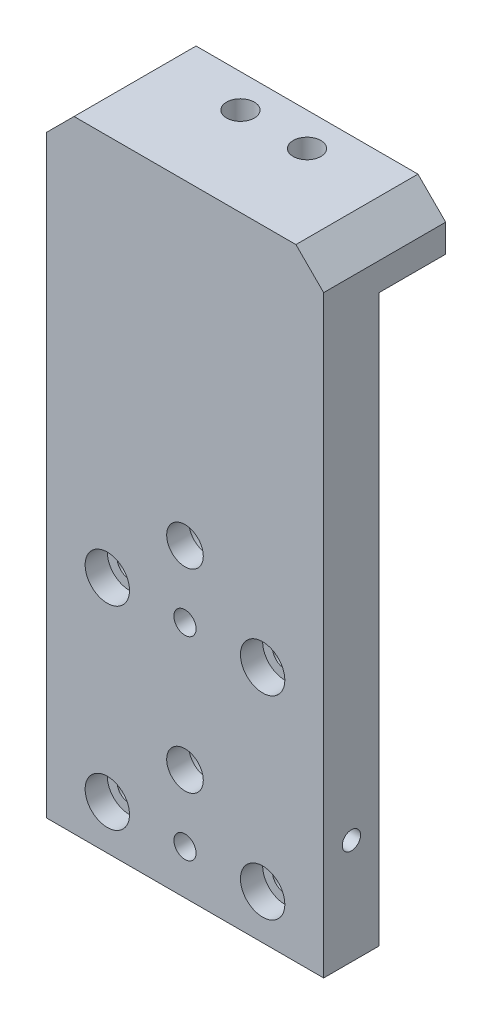
from build123d import *

# Parameters (mm, degrees)
SKETCH1_W             = 50
SKETCH1_H             = 112
SKETCH1_R             = 3.3
SKETCH1_R_2           = 2
SKETCH1_R_3           = 2.25
BOSS_EXTRUDE1_DEPTH   = 10
SKETCH2_R             = 5.5
CUT_EXTRUDE1_DEPTH    = 6
SKETCH3_R             = 4
CUT_EXTRUDE2_DEPTH    = 4
SKETCH4_W             = 50
SKETCH4_H             = 10
BOSS_EXTRUDE2_DEPTH   = 12
M4_TAPPED_HOLE1_D     = 3.3
M4_TAPPED_HOLE1_DEPTH = 8
M4_TAPPED_HOLE1_TIP   = 0.991420021
M4_TAPPED_HOLE2_D     = 3.3
M4_TAPPED_HOLE2_DEPTH = 8
M4_TAPPED_HOLE2_TIP   = 0.991420021
CHAMFER1_SIZE         = 5
M6_TAPPED_HOLE1_D     = 5
M6_TAPPED_HOLE1_DEPTH = 15
M6_TAPPED_HOLE1_TIP   = 1.502151548


with BuildPart() as part:
    # Sketch1 → Boss-Extrude1 (new body)
    with BuildSketch(Plane.XY):
        with Locations((4.323308271, -31.845864662)):
            Rectangle(SKETCH1_W, SKETCH1_H)
        with Locations((4.323308271, -67.845864662)):
            Circle(SKETCH1_R, mode=Mode.SUBTRACT)
        with Locations((4.323308271, -44.845864662)):
            Circle(SKETCH1_R_2, mode=Mode.SUBTRACT)
        with Locations((4.323308271, -32.845864662)):
            Circle(SKETCH1_R, mode=Mode.SUBTRACT)
        with Locations((18.323308271, -79.845864662)):
            Circle(SKETCH1_R_3, mode=Mode.SUBTRACT)
        with Locations((-9.676691729, -79.845864662)):
            Circle(SKETCH1_R_3, mode=Mode.SUBTRACT)
        with Locations((-9.676691729, -44.845864662)):
            Circle(SKETCH1_R_3, mode=Mode.SUBTRACT)
        with Locations((18.323308271, -44.845864662)):
            Circle(SKETCH1_R_3, mode=Mode.SUBTRACT)
        with Locations((4.323308271, -79.845864662)):
            Circle(SKETCH1_R_2, mode=Mode.SUBTRACT)
    extrude(amount=BOSS_EXTRUDE1_DEPTH)

    # Sketch2 → Cut-Extrude1 (cut)
    with BuildSketch(Plane(origin=(0, 0, 0), x_dir=(-1, 0, 0), z_dir=(0, 0, -1))):
        with Locations((-4.323308271, -32.845864662)):
            Circle(SKETCH2_R)
        with Locations((-4.323308271, -67.845864662)):
            Circle(SKETCH2_R)
    extrude(amount=-CUT_EXTRUDE1_DEPTH, mode=Mode.SUBTRACT)

    # Sketch3 → Cut-Extrude2 (cut)
    with BuildSketch(Plane.XY.offset(10)):
        with Locations((-9.676691729, -44.845864662)):
            Circle(SKETCH3_R)
        with Locations((18.323308271, -44.845864662)):
            Circle(SKETCH3_R)
        with Locations((18.323308271, -79.845864662)):
            Circle(SKETCH3_R)
        with Locations((-9.676691729, -79.845864662)):
            Circle(SKETCH3_R)
    extrude(amount=-CUT_EXTRUDE2_DEPTH, mode=Mode.SUBTRACT)

    # Sketch4 → Boss-Extrude2 (add)
    with BuildSketch(Plane(origin=(0, 0, 0), x_dir=(-1, 0, 0), z_dir=(0, 0, -1))):
        with Locations((-4.323308271, 19.154135338)):
            Rectangle(SKETCH4_W, SKETCH4_H)
    extrude(amount=BOSS_EXTRUDE2_DEPTH)

    # M4 Tapped Hole1
    with Locations(Plane(origin=(29.323308271, 0, 0), x_dir=(0, 0, -1), z_dir=(1, 0, 0))):
        with Locations((-5, -68.845864662)):
            Hole(M4_TAPPED_HOLE1_D / 2, depth=M4_TAPPED_HOLE1_DEPTH)
            with Locations((0, 0, -(M4_TAPPED_HOLE1_DEPTH + M4_TAPPED_HOLE1_TIP / 2))):  # 118° drill point
                Cone(0, M4_TAPPED_HOLE1_D / 2, M4_TAPPED_HOLE1_TIP, mode=Mode.SUBTRACT)

    # M4 Tapped Hole2
    with Locations(Plane.ZY.offset(20.676691729)):
        with Locations((5, -68.845864662)):
            Hole(M4_TAPPED_HOLE2_D / 2, depth=M4_TAPPED_HOLE2_DEPTH)
            with Locations((0, 0, -(M4_TAPPED_HOLE2_DEPTH + M4_TAPPED_HOLE2_TIP / 2))):  # 118° drill point
                Cone(0, M4_TAPPED_HOLE2_D / 2, M4_TAPPED_HOLE2_TIP, mode=Mode.SUBTRACT)

    # Chamfer1
    chamfer1_edges = [part.edges().sort_by_distance(p)[0] for p in [
        (-20.676691729, 24.154135338, -1),
        (29.323308271, 24.154135338, -1),
    ]]
    chamfer(chamfer1_edges, length=CHAMFER1_SIZE)

    # M6 Tapped Hole1
    with Locations(Plane(origin=(0, 24.154135338, 0), x_dir=(1, 0, 0), z_dir=(0, 1, 0))):
        with Locations((10.323308271, 6), (-1.676691729, 6)):
            Hole(M6_TAPPED_HOLE1_D / 2, depth=M6_TAPPED_HOLE1_DEPTH)
            with Locations((0, 0, -(M6_TAPPED_HOLE1_DEPTH + M6_TAPPED_HOLE1_TIP / 2))):  # 118° drill point
                Cone(0, M6_TAPPED_HOLE1_D / 2, M6_TAPPED_HOLE1_TIP, mode=Mode.SUBTRACT)


solid = part.part
